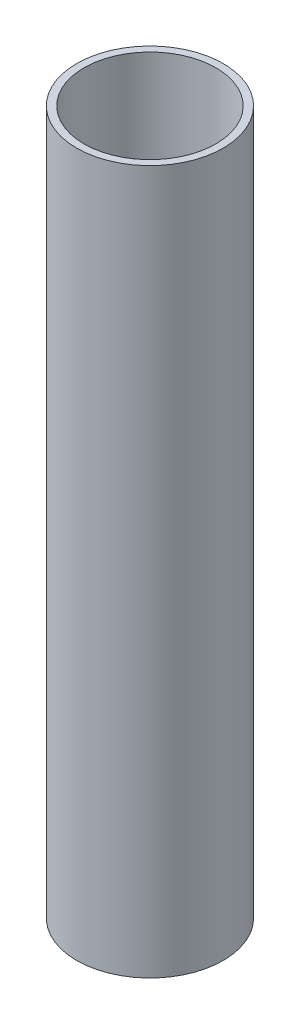
from build123d import *

# Parameters (mm, degrees)
SKETCH1_R           = 31.75
BOSS_EXTRUDE1_DEPTH = 304.8
SKETCH2_R           = 28.575
CUT_EXTRUDE1_DEPTH  = 305.8


with BuildPart() as part:
    # Sketch1 → Boss-Extrude1 (new body)
    with BuildSketch(Plane(origin=(0, 0, 0), x_dir=(1, 0, 0), z_dir=(0, 1, 0))):
        Circle(SKETCH1_R)
    extrude(amount=-BOSS_EXTRUDE1_DEPTH)

    # Sketch2 → Cut-Extrude1 (cut, through all)
    with BuildSketch(Plane(origin=(0, 0, 0), x_dir=(1, 0, 0), z_dir=(0, 1, 0))):
        Circle(SKETCH2_R)
    extrude(amount=-CUT_EXTRUDE1_DEPTH, mode=Mode.SUBTRACT)


solid = part.part
